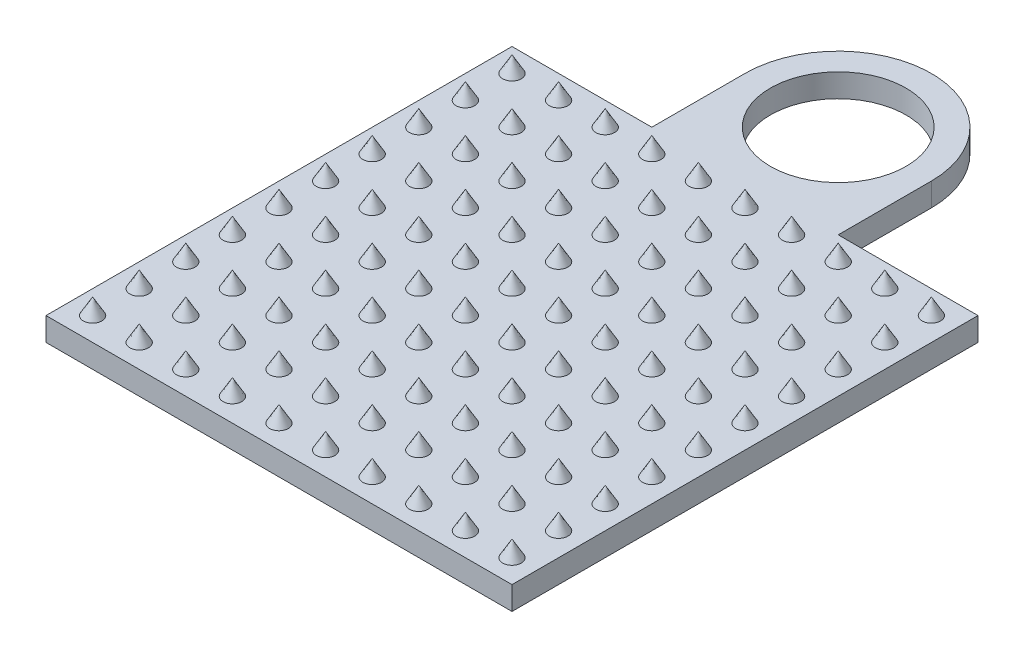
from build123d import *

# Parameters (mm, degrees)
SKETCH1_W               = 10
SKETCH1_H               = 10
PLATE_DEPTH             = 0.5
BOSS_EXTRUDE3_DEPTH     = 0.5
CUT_EXTRUDE1_DEPTH      = 0.5
CUT_EXTRUDE1_DEPTH_BACK = 1.5
SKETCH5_R               = 1.455938962
LPATTERN1_COUNT         = 10
LPATTERN1_PITCH         = 1
LPATTERN1_COUNT_DIR2    = 10
LPATTERN1_PITCH_DIR2    = 1


with BuildPart() as part:
    # Sketch1 → Plate (new body)
    with BuildSketch(Plane(origin=(0, 0, 0), x_dir=(1, 0, 0), z_dir=(0, 1, 0))):
        Rectangle(SKETCH1_W, SKETCH1_H)
    extrude(amount=PLATE_DEPTH)

    # Sketch4 → Boss-Extrude3 (add)
    with BuildSketch(Plane(origin=(0, 0, 0), x_dir=(1, 0, 0), z_dir=(0, 1, 0))):
        with BuildLine():
            Line((-2, 7), (-2, 5))
            Line((-2, 5), (2, 5))
            Line((2, 5), (2, 7))
            ThreePointArc((2, 7), (0, 9), (-2, 7))
        make_face()
    extrude(amount=BOSS_EXTRUDE3_DEPTH)

    # Sketch5 → Cut-Extrude1 (cut, two sides: drawn at the far end of the back side and taken through both)
    with BuildSketch(Plane(origin=(0, 0.5, 0), x_dir=(1, 0, 0), z_dir=(0, 1, 0)).offset(-CUT_EXTRUDE1_DEPTH_BACK)):
        with Locations(Location((0, 7, 0), (0, 0, 270))):
            Circle(SKETCH5_R)
    extrude(amount=CUT_EXTRUDE1_DEPTH + CUT_EXTRUDE1_DEPTH_BACK, mode=Mode.SUBTRACT)

    # Cone cone 1 section (through the dimple's axis) → Cone (revolve)
    with BuildSketch(Plane(origin=(-4.5, 0.5, 4.5), x_dir=(0, 0, -1), z_dir=(1, 0, 0))):
        Polygon((0, 0), (0.2, 0), (0, 0.346410162), align=None)
    cone = revolve(axis=Axis((-4.5, 0.5, 4.5), (0, 1, 0)))

    # LPattern1: Cone 10 × 10
    with Locations(*[(i * LPATTERN1_PITCH, 0, -j * LPATTERN1_PITCH_DIR2) for i in range(LPATTERN1_COUNT) for j in range(LPATTERN1_COUNT_DIR2) if (i, j) != (0, 0)]):
        add(cone)


solid = part.part
